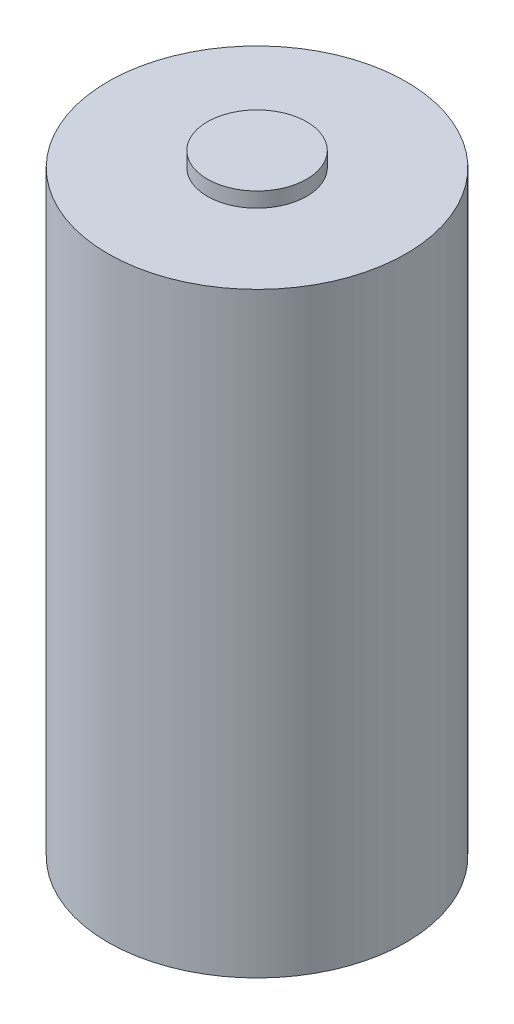
from build123d import *

# Parameters (mm, degrees)
SKETCH2_R           = 3
BOSS_EXTRUDE1_DEPTH = 12
SKETCH3_R           = 1
BOSS_EXTRUDE2_DEPTH = 0.3
SKETCH4_R           = 0.25
CUT_EXTRUDE1_DEPTH  = 0.1


with BuildPart() as part:
    # Sketch2 → Boss-Extrude1 (new body)
    with BuildSketch(Plane(origin=(0, 0, 0), x_dir=(1, 0, 0), z_dir=(0, 1, 0))):
        Circle(SKETCH2_R)
    extrude(amount=BOSS_EXTRUDE1_DEPTH)

    # Sketch3 → Boss-Extrude2 (add)
    with BuildSketch(Plane(origin=(0, 12, 0), x_dir=(1, 0, 0), z_dir=(0, 1, 0))):
        Circle(SKETCH3_R)
    extrude(amount=BOSS_EXTRUDE2_DEPTH)

    # Sketch4 → Cut-Extrude1 (cut)
    with BuildSketch(Plane(origin=(0, 0, 0), x_dir=(-1, 0, 0), z_dir=(0, -1, 0))):
        with Locations((0, 2)):
            Circle(SKETCH4_R)
        with Locations((0, -2)):
            Circle(SKETCH4_R)
    extrude(amount=-CUT_EXTRUDE1_DEPTH, mode=Mode.SUBTRACT)


solid = part.part
